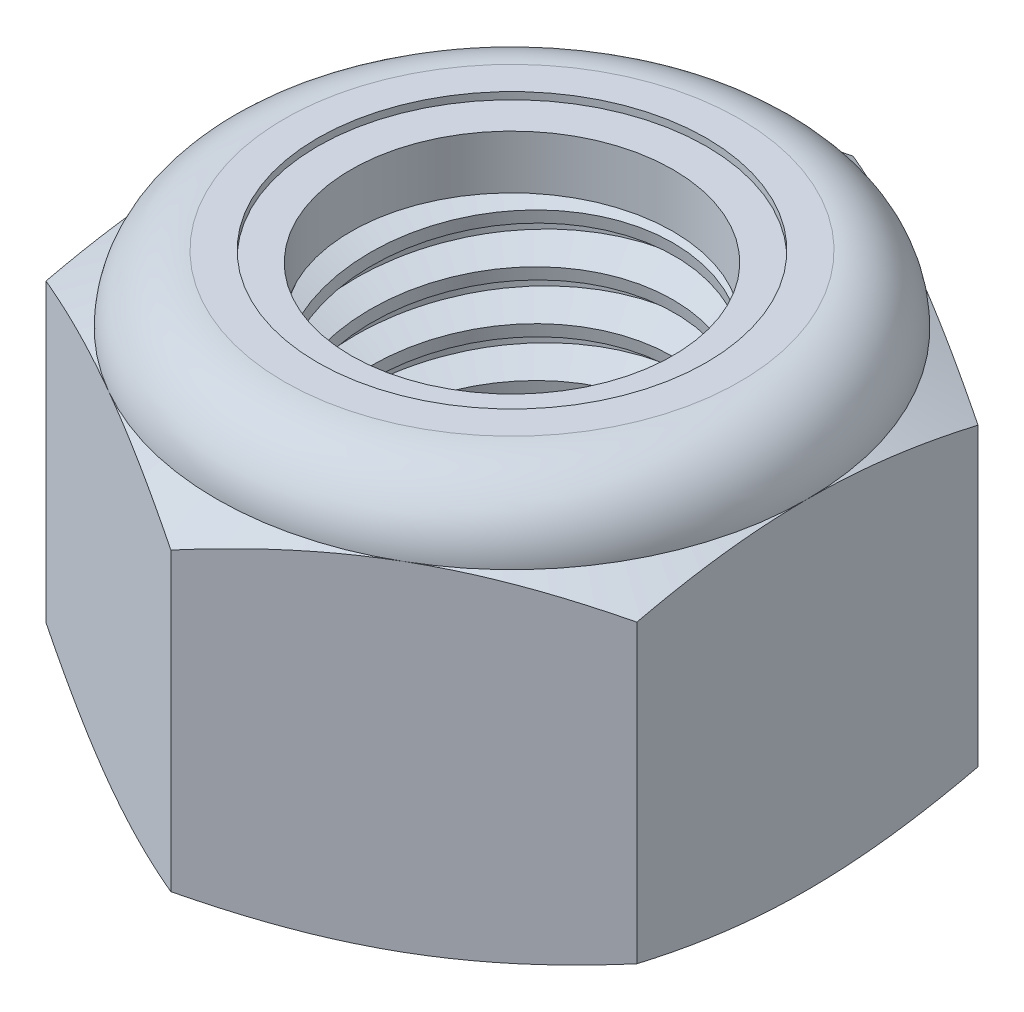
from build123d import *

# Parameters (mm, degrees)
EXTRUDE1_DEPTH      = 8.73125
SKETCH2_W           = 3.96875
SKETCH2_H           = 8.73125
LPATTERN1_COUNT     = 8
LPATTERN1_PITCH     = 1.058333333
LPATTERN1_COL_COUNT = 2
LPATTERN1_COL_PITCH = 1.058333333


with BuildPart() as part:
    # Sketch1 → Extrude1 (new body)
    with BuildSketch(Plane(origin=(0, 0, 0), x_dir=(1, 0, 0), z_dir=(0, 1, 0))):
        Polygon((0, 7.332348419), (-6.35, 3.666174209), (-6.35, -3.666174209), (0, -7.332348419), (6.35, -3.666174209), (6.35, 3.666174209), align=None)
    extrude(amount=EXTRUDE1_DEPTH)

    # Sketch4 → Cut-Revolve2 (revolve, cut)
    with BuildSketch(Plane(origin=(0, 0, 0), x_dir=(0, 0, -1), z_dir=(1, 0, 0))):
        Polygon((0, 8.73125), (3.96875, 8.73125), (3.462129843, 8.495009141), (3.462129843, 0.236240859), (3.96875, 0), (0, 0), align=None)
    revolve(axis=Axis((0, 8.73125, 0), (0, 1, 0)), mode=Mode.SUBTRACT)


with BuildPart() as body_2:
    # Sketch2 → Revolve1 (revolve)
    with BuildSketch(Plane(origin=(0, 0, 0), x_dir=(0, 0, -1), z_dir=(1, 0, 0))):
        with Locations((1.984375, 4.365625)):
            Rectangle(SKETCH2_W, SKETCH2_H)
    revolve(axis=Axis((0, -3.96875, 0), (0, 1, 0)))

    # Sketch3 → Cut-Revolve1 (revolve, cut)
    with BuildSketch(Plane(origin=(0, 0, 0), x_dir=(0, 0, -1), z_dir=(1, 0, 0))):
        Polygon((3.986234159, 8.600118809), (4.10862327, 7.682200472), (3.49709816, 7.934319821), (3.462129843, 8.196582203), align=None)
    cut_revolve1 = revolve(axis=Axis((0, 8.73125, 0.150633003), (0, -0.991227901, -0.13216372)), mode=Mode.SUBTRACT)

    # LPattern1: Cut-Revolve1 ×8
    with Locations(*[(0, -i * LPATTERN1_PITCH, 0) for i in range(1, LPATTERN1_COUNT)]):
        add(cut_revolve1, mode=Mode.SUBTRACT)

    # LPattern1 col: Cut-Revolve1 ×2
    with Locations(*[(0, i * LPATTERN1_COL_PITCH, 0) for i in range(1, LPATTERN1_COL_COUNT)]):
        add(cut_revolve1, mode=Mode.SUBTRACT)


with BuildPart() as part_1:
    add(part.part)

    # Combine1: cut body 2
    add(body_2.part, mode=Mode.SUBTRACT)

    # Sketch5 → Cut-Revolve3 (revolve, cut)
    with BuildSketch(Plane(origin=(0, 0, 0), x_dir=(0, 0, -1), z_dir=(1, 0, 0))):
        with BuildLine():
            Line((0, 0), (6.35, 0))
            Line((6.35, 0), (7.332348419, 0.458076591))
            Line((7.332348419, 0.458076591), (7.332348419, 6.817965076))
            Line((7.332348419, 6.817965076), (6.35, 7.276041667))
            ThreePointArc((6.35, 7.276041667), (5.923779347, 8.305029347), (4.894791667, 8.73125))
            Line((4.894791667, 8.73125), (4.894791667, 10.00125))
            Line((4.894791667, 10.00125), (8.602348419, 10.00125))
            Line((8.602348419, 10.00125), (8.602348419, -1.27))
            Line((8.602348419, -1.27), (0, -1.27))
            Line((0, -1.27), (0, 0))
        make_face()
    revolve(axis=Axis((0, 0, 0), (0, 1, 0)), mode=Mode.SUBTRACT)

    # Sketch6 → Cut-Revolve4 (revolve, cut)
    with BuildSketch(Plane(origin=(0, 0, 0), x_dir=(0, 0, -1), z_dir=(1, 0, 0))):
        with BuildLine():
            Line((0, 7.276041667), (6.1976, 7.276041667))
            ThreePointArc((6.1976, 7.276041667), (5.816016274, 8.197266274), (4.894791667, 8.57885))
            Line((4.894791667, 8.57885), (4.178460755, 8.57885))
            Line((4.178460755, 8.57885), (4.178460755, 10.00125))
            Line((4.178460755, 10.00125), (0, 10.00125))
            Line((0, 10.00125), (0, 7.276041667))
        make_face()
    revolve(axis=Axis((0, 10.00125, 0), (0, 1, 0)), mode=Mode.SUBTRACT)


with BuildPart() as body_2_2:
    # Sketch7 → Revolve2 (revolve)
    with BuildSketch(Plane(origin=(0, 0, 0), x_dir=(0, 0, -1), z_dir=(1, 0, 0))):
        with BuildLine():
            Line((3.462129843, 7.352241667), (6.119030844, 7.352241667))
            ThreePointArc((6.119030844, 7.352241667), (5.734762038, 8.169919611), (4.894791667, 8.50265))
            Line((4.894791667, 8.50265), (3.462129843, 8.50265))
            Line((3.462129843, 8.50265), (3.462129843, 7.352241667))
        make_face()
    revolve(axis=Axis((0, 7.352241667, 0), (0, 1, 0)))


solid = Compound([part_1.part, body_2_2.part])
